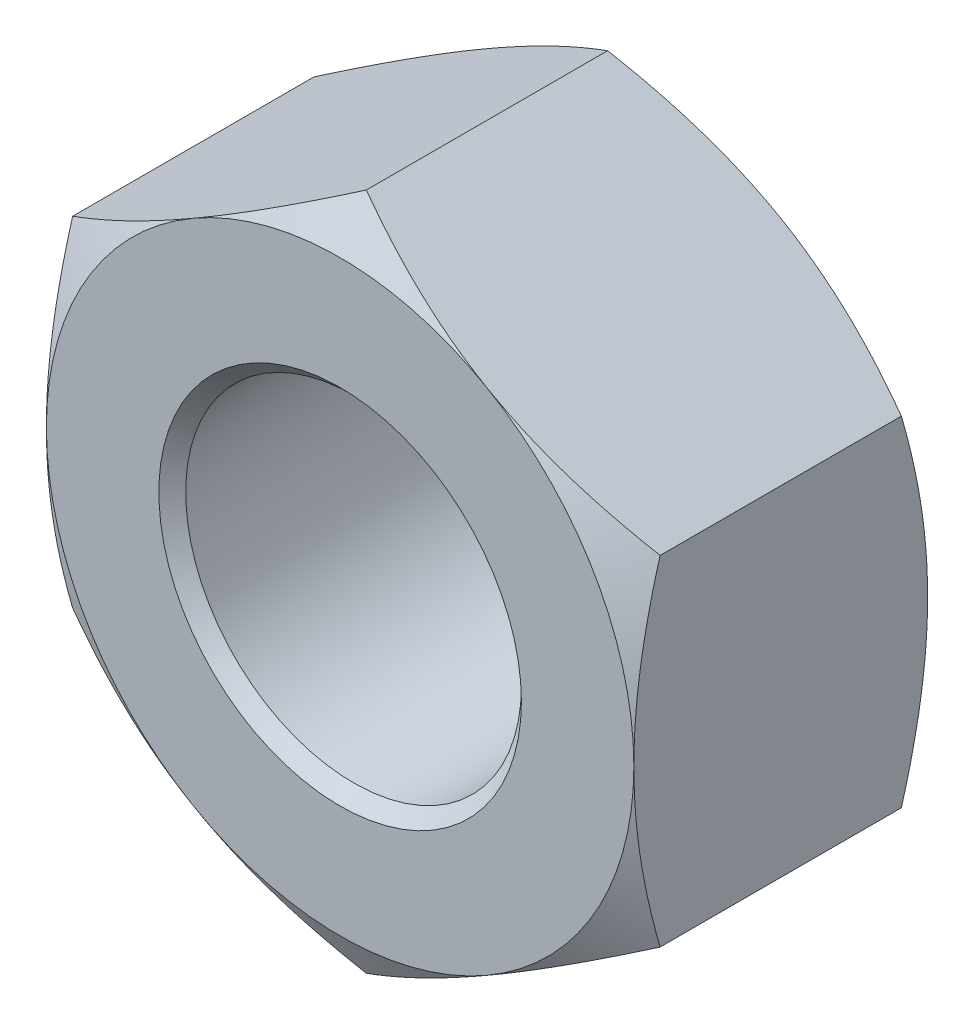
from build123d import *

# Parameters (mm, degrees)
SKETCH1_R               = 3.175
EXTRUDE1_DEPTH          = 2.778125
SKETCH9_OUTSIDE_W       = 55.29
SKETCH9_OUTSIDE_H       = 57.01
SKETCH9_OUTSIDE_R       = 5.55625
CUT_EXTRUDE2_DEPTH      = 11.1442782
CUT_EXTRUDE2_DRAFT      = -60
MIRROR2_COPY_1_SKETCH_W = 55.29
MIRROR2_COPY_1_SKETCH_H = 57.01
MIRROR2_COPY_1_SKETCH_R = 5.55625
MIRROR2_COPY_1_DEPTH    = 11.1442782
MIRROR2_COPY_1_DRAFT    = -60


with BuildPart() as part:
    # Sketch1 → Extrude1 (new, symmetric)
    with BuildSketch(Plane.XY):
        Polygon((-5.55625, 3.207902433), (-5.55625, -3.207902433), (0, -6.415804866), (5.55625, -3.207902433), (5.55625, 3.207902433), (0, 6.415804866), align=None)
        Circle(SKETCH1_R, mode=Mode.SUBTRACT)
    extrude(amount=EXTRUDE1_DEPTH, both=True)


with BuildPart() as cut_extrude2_tool:
    # Sketch9 outside → Cut-Extrude2 (with draft: the straight prism first)
    with BuildSketch(Plane.XY.offset(2.778125)):
        Rectangle(SKETCH9_OUTSIDE_W, SKETCH9_OUTSIDE_H)
        Circle(SKETCH9_OUTSIDE_R, mode=Mode.SUBTRACT)
    extrude(amount=-CUT_EXTRUDE2_DEPTH)
    # Cut-Extrude2: the draft: its side faces are tilted about the plane it starts from
    cut_extrude2_sides = [cut_extrude2_tool.faces().sort_by_distance(p)[0] for p in [
        (0, -28.505, -2.7940141),
        (27.645, 0, -2.7940141),
        (0, 28.505, -2.7940141),
        (-27.645, 0, -2.7940141),
        (-5.55625, 0, -2.7940141),
    ]]
    draft(cut_extrude2_sides, Plane.XY.offset(2.778125), CUT_EXTRUDE2_DRAFT)


with BuildPart() as part_1:
    add(part.part)

    # Cut-Extrude2: cut by cut_extrude2_tool
    add(cut_extrude2_tool.part, mode=Mode.SUBTRACT)


with BuildPart() as mirror2_copy_1_tool:
    # Mirror2 copy 1 sketch → Mirror2 copy 1 (with draft: the straight prism first)
    with BuildSketch(Plane(origin=(0, 0, -2.778125), x_dir=(1, 0, 0), z_dir=(0, 0, -1))):
        Rectangle(MIRROR2_COPY_1_SKETCH_W, MIRROR2_COPY_1_SKETCH_H)
        Circle(MIRROR2_COPY_1_SKETCH_R, mode=Mode.SUBTRACT)
    extrude(amount=-MIRROR2_COPY_1_DEPTH)
    # Mirror2 copy 1: the draft: its side faces are tilted about the plane it starts from
    mirror2_copy_1_sides = [mirror2_copy_1_tool.faces().sort_by_distance(p)[0] for p in [
        (0, -28.505, 2.7940141),
        (27.645, 0, 2.7940141),
        (0, 28.505, 2.7940141),
        (-27.645, 0, 2.7940141),
        (-5.55625, 0, 2.7940141),
    ]]
    draft(mirror2_copy_1_sides, Plane(origin=(0, 0, -2.778125), x_dir=(1, 0, 0), z_dir=(0, 0, -1)), MIRROR2_COPY_1_DRAFT)


with BuildPart() as part_2:
    add(part_1.part)

    # Mirror2 copy 1: cut by mirror2_copy_1_tool
    add(mirror2_copy_1_tool.part, mode=Mode.SUBTRACT)

    # Cut-Extrude10 cone 1 section (through the dimple's axis) → Cut-Extrude10 (revolve, cut)
    with BuildSketch(Plane(origin=(0, 0, 2.778125), x_dir=(0, -1, 0), z_dir=(1, 0, 0))):
        Polygon((0, 0), (3.429, 0), (0, 3.429), align=None)
    revolve(axis=Axis((0, 0, 2.778125), (0, 0, -1)), mode=Mode.SUBTRACT)


solid = part_2.part
